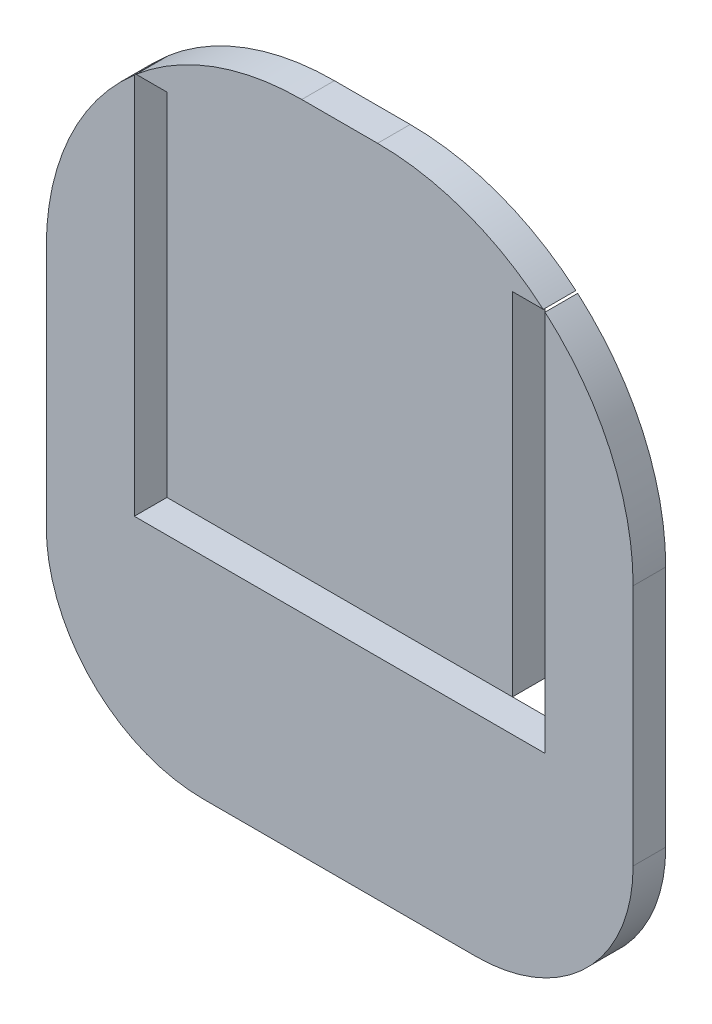
from build123d import *

# Parameters (mm, degrees)
BOSS_EXTRUDE1_DEPTH = 4.3
CUT_EXTRUDE1_DEPTH  = 10


with BuildPart() as part:
    # Sketch1 → Boss-Extrude1 (new body)
    with BuildSketch(Plane.XY):
        with BuildLine():
            Line((-18, -82.2), (-0.5, -82.2))
            Line((-0.5, -82.2), (0.5, -82.2))
            Line((0.5, -82.2), (18, -82.2))
            ThreePointArc((18, -82.2), (32.637110371, -76.137110371), (38.7, -61.5))
            Line((38.7, -61.5), (38.7, -29.5))
            ThreePointArc((38.7, -29.5), (28.829498526, -5.670501474), (5, 4.2))
            Line((5, 4.2), (-5, 4.2))
            ThreePointArc((-5, 4.2), (-28.829498526, -5.670501474), (-38.7, -29.5))
            Line((-38.7, -29.5), (-38.7, -61.5))
            ThreePointArc((-38.7, -61.5), (-32.637110371, -76.137110371), (-18, -82.2))
        make_face()
    extrude(amount=BOSS_EXTRUDE1_DEPTH)

    # Sketch2 → Cut-Extrude1 (cut)
    with BuildSketch(Plane.XY.offset(4.3)):
        Polygon((-27.085, -4.045279907), (-27.085, -3.845279907), (-22.785, -3.845279907), (-22.785, -50.145279907), (22.785, -50.145279907), (22.785, -3.845279907), (27.085, -3.845279907), (27.085, -4.045279907), (27.085, -54.445279907), (-27.085, -54.445279907), align=None)
    extrude(amount=-CUT_EXTRUDE1_DEPTH, mode=Mode.SUBTRACT)


solid = part.part
